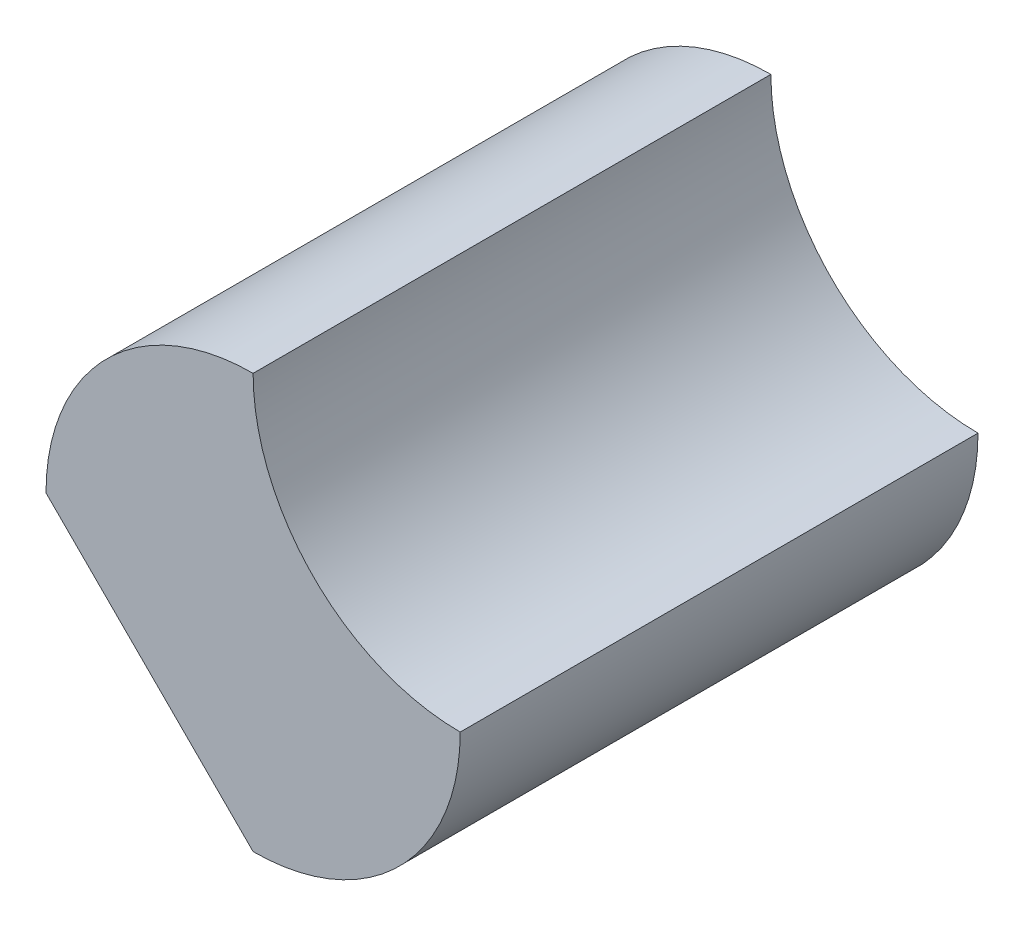
from build123d import *

# Parameters (mm, degrees)
BOSS_EXTRUDE1_DEPTH = 25


with BuildPart() as part:
    # Sketch1 → Boss-Extrude1 (new body)
    with BuildSketch(Plane.XY):
        with BuildLine():
            Line((-10, 10), (0, 0))
            ThreePointArc((0, 0), (7.071067812, 2.928932188), (10, 10))
            ThreePointArc((10, 10), (2.928932188, 12.928932188), (0, 20))
            ThreePointArc((0, 20), (-7.071067812, 17.071067812), (-10, 10))
        make_face()
    extrude(amount=BOSS_EXTRUDE1_DEPTH)


solid = part.part
